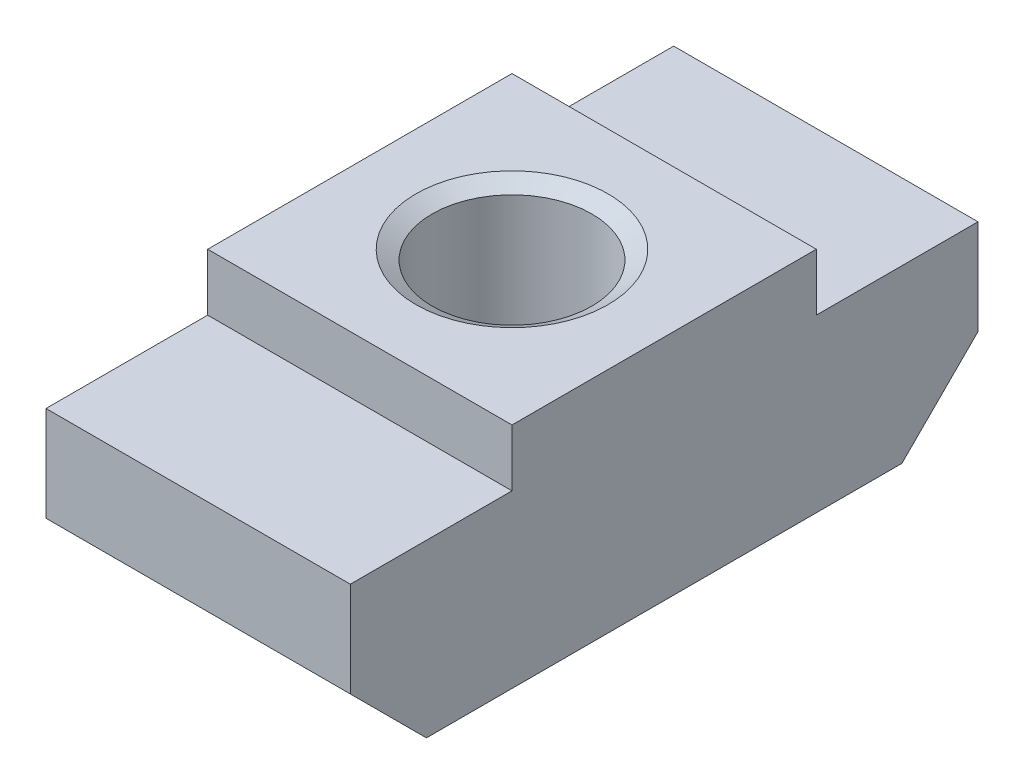
from build123d import *

# Parameters (mm, degrees)
SCHIZZO1_W                      = 8
SCHIZZO1_H                      = 6
ESTRUSIONE_ESTRUSIONE1_DEPTH    = 16.5
FORO_FILETTATO_M5_1_D           = 4.2
FORO_FILETTATO_M5_1_CSINK_D     = 5.05
FORO_FILETTATO_M5_1_CSINK_ANGLE = 120
SCHIZZO4_W                      = 4.25
SCHIZZO4_H                      = 1.5
TAGLIO_ESTRUSIONE1_DEPTH        = 10


with BuildPart() as part:
    # Schizzo1 → Estrusione-Estrusione1 (new body)
    with BuildSketch(Plane.XY):
        with Locations((0, 3)):
            Rectangle(SCHIZZO1_W, SCHIZZO1_H)
    extrude(amount=ESTRUSIONE_ESTRUSIONE1_DEPTH)

    # Foro filettato M5-1 (through all)
    with Locations(Plane(origin=(0, 6, 0), x_dir=(1, 0, 0), z_dir=(0, 1, 0))):
        with Locations((0, -8.25)):
            CounterSinkHole(FORO_FILETTATO_M5_1_D / 2, FORO_FILETTATO_M5_1_CSINK_D / 2, counter_sink_angle=FORO_FILETTATO_M5_1_CSINK_ANGLE)

    # Schizzo4 → Taglio-Estrusione1 (cut)
    with BuildSketch(Plane(origin=(4, 0, 0), x_dir=(0, 0, -1), z_dir=(1, 0, 0))):
        Polygon((-16.5, 0), (-16.5, 2), (-14.5, 0), align=None)
        Polygon((0, 0), (0, 2), (-2, 0), align=None)
        with Locations((-2.125, 5.25)):
            Rectangle(SCHIZZO4_W, SCHIZZO4_H)
        with Locations((-14.375, 5.25)):
            Rectangle(SCHIZZO4_W, SCHIZZO4_H)
    extrude(amount=-TAGLIO_ESTRUSIONE1_DEPTH, mode=Mode.SUBTRACT)


solid = part.part
